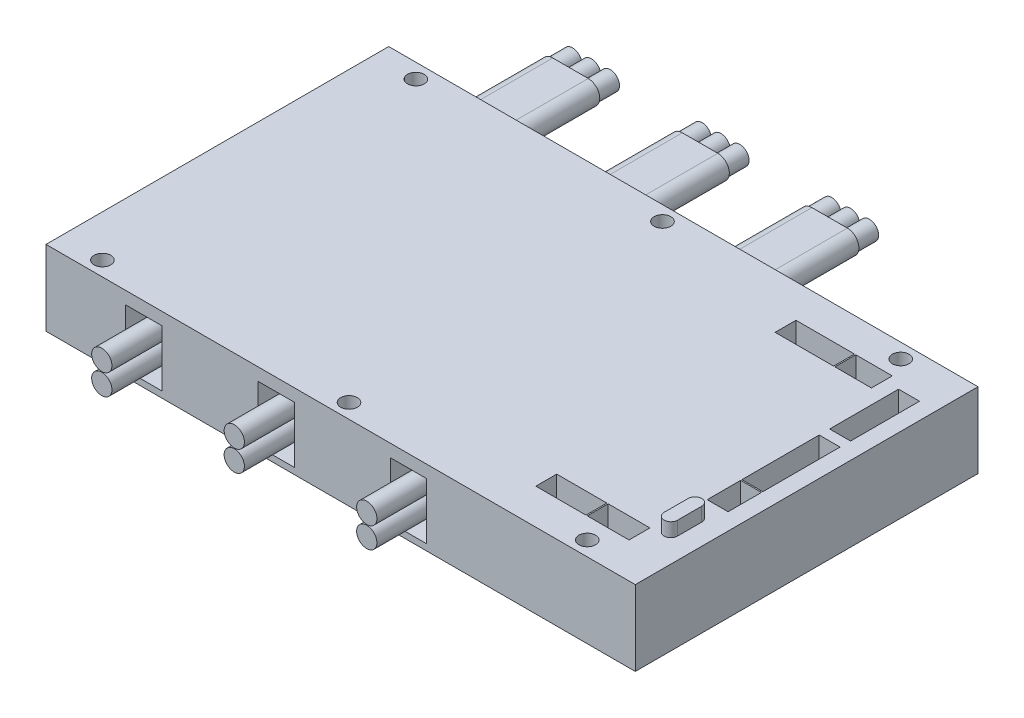
from build123d import *

# Parameters (mm, degrees)
SKETCH1_W           = 141
SKETCH1_H           = 82
BOSS_EXTRUDE1_DEPTH = 9
SKETCH3_R           = 2
CUT_EXTRUDE1_DEPTH  = 19
SKETCH4_W           = 8.7
SKETCH4_H           = 13.5
CUT_EXTRUDE2_DEPTH  = 10
SKETCH5_W           = 20
SKETCH5_H           = 5
CUT_EXTRUDE3_DEPTH  = 10
SKETCH6_W           = 3.23
SKETCH6_H           = 5.77
BOSS_EXTRUDE2_DEPTH = 3.3
SKETCH7_R           = 2.425
BOSS_EXTRUDE3_DEPTH = 20
LPATTERN1_COUNT     = 3
LPATTERN1_PITCH     = 31.7
SKETCH8_W           = 8.5
SKETCH8_H           = 5
SKETCH8_H_2         = 0.25
BOSS_EXTRUDE4_DEPTH = 30
SKETCH10_R          = 2.225
BOSS_EXTRUDE6_DEPTH = 5
LPATTERN2_COUNT     = 3
LPATTERN2_PITCH     = 31
SKETCH9_W           = 12
SKETCH9_H           = 5
SKETCH9_W_2         = 10
SKETCH9_W_3         = 5
SKETCH9_H_2         = 8
SKETCH9_H_3         = 18.5
SKETCH9_H_4         = 16.5
SKETCH9_W_4         = 8.75
SKETCH9_W_5         = 14
CUT_EXTRUDE4_DEPTH  = 5


with BuildPart() as part:
    # Sketch1 → Boss-Extrude1 (new body, symmetric)
    with BuildSketch(Plane(origin=(0, 0, 0), x_dir=(1, 0, 0), z_dir=(0, 1, 0))):
        Rectangle(SKETCH1_W, SKETCH1_H)
    extrude(amount=BOSS_EXTRUDE1_DEPTH, both=True)

    # Sketch3 → Cut-Extrude1 (cut, through all)
    with BuildSketch(Plane(origin=(0, 9, 0), x_dir=(1, 0, 0), z_dir=(0, 1, 0))):
        with Locations((-60.5, 37.5)):
            Circle(SKETCH3_R)
        with Locations((-1.5, 37.5)):
            Circle(SKETCH3_R)
        with Locations((55.5, 37.5)):
            Circle(SKETCH3_R)
    cut_extrude1 = extrude(amount=-CUT_EXTRUDE1_DEPTH, mode=Mode.SUBTRACT)

    # Mirror1: Cut-Extrude1 across plane
    add(cut_extrude1.mirror(Plane.XY), mode=Mode.SUBTRACT)

    # Sketch4 → Cut-Extrude2 (cut)
    with BuildSketch(Plane.XY.offset(41)):
        with Locations((-47.15, -0.75)):
            Rectangle(SKETCH4_W, SKETCH4_H)
        with Locations((-15.45, -0.75)):
            Rectangle(SKETCH4_W, SKETCH4_H)
        with Locations((16.25, -0.75)):
            Rectangle(SKETCH4_W, SKETCH4_H)
    extrude(amount=-CUT_EXTRUDE2_DEPTH, mode=Mode.SUBTRACT)

    # Sketch5 → Cut-Extrude3 (cut)
    with BuildSketch(Plane(origin=(0, 0, -41), x_dir=(-1, 0, 0), z_dir=(0, 0, -1))):
        with Locations((47, 3.5)):
            Rectangle(SKETCH5_W, SKETCH5_H)
        with Locations((16, 3.5)):
            Rectangle(SKETCH5_W, SKETCH5_H)
        with Locations((-15, 3.5)):
            Rectangle(SKETCH5_W, SKETCH5_H)
    extrude(amount=-CUT_EXTRUDE3_DEPTH, mode=Mode.SUBTRACT)

    # Sketch6 → Boss-Extrude2 (add)
    with BuildSketch(Plane(origin=(0, 9, 0), x_dir=(1, 0, 0), z_dir=(0, 1, 0))):
        with Locations((63.885, -23)):
            Rectangle(SKETCH6_W, SKETCH6_H)
        with BuildLine():
            Line((62.27, -20.115), (65.5, -20.115))
            ThreePointArc((65.5, -20.115), (63.885, -18.5), (62.27, -20.115))
        make_face()
        with BuildLine():
            ThreePointArc((65.5, -25.885), (63.885, -27.5), (62.27, -25.885))
            Line((62.27, -25.885), (65.5, -25.885))
        make_face()
    extrude(amount=BOSS_EXTRUDE2_DEPTH)

    # Sketch7 → Boss-Extrude3 (add)
    with BuildSketch(Plane.XY.offset(31)):
        with Locations((-47.15, 1.75)):
            Circle(SKETCH7_R)
        with Locations((-47.15, -3.25)):
            Circle(SKETCH7_R)
    boss_extrude3 = extrude(amount=BOSS_EXTRUDE3_DEPTH)

    # LPattern1: Boss-Extrude3 ×3
    with Locations(*[(i * LPATTERN1_PITCH, 0, 0) for i in range(1, LPATTERN1_COUNT)]):
        add(boss_extrude3)

    # Sketch8 → Boss-Extrude4 (add)
    with BuildSketch(Plane(origin=(0, 0, -31), x_dir=(-1, 0, 0), z_dir=(0, 0, -1))):
        with Locations((47, 3.5)):
            Rectangle(SKETCH8_W, SKETCH8_H)
        with BuildLine():
            Line((51.25, 6), (51.25, 1))
            Line((51.25, 1), (52.395643924, 1))
            ThreePointArc((52.395643924, 1), (54, 3.5), (52.395643924, 6))
            Line((52.395643924, 6), (51.25, 6))
        make_face()
        with BuildLine():
            Line((41.604356076, 1), (42.75, 1))
            Line((42.75, 1), (42.75, 6))
            Line((42.75, 6), (41.604356076, 6))
            ThreePointArc((41.604356076, 6), (40, 3.5), (41.604356076, 1))
        make_face()
        with Locations((47, 6.125)):
            Rectangle(SKETCH8_W, SKETCH8_H_2)
        with BuildLine():
            Line((51.25, 6.25), (51.25, 6))
            Line((51.25, 6), (52.395643924, 6))
            ThreePointArc((52.395643924, 6), (51.83630197, 6.186773158), (51.25, 6.25))
        make_face()
        with BuildLine():
            Line((41.604356076, 6), (42.75, 6))
            Line((42.75, 6), (42.75, 6.25))
            ThreePointArc((42.75, 6.25), (42.16369803, 6.186773158), (41.604356076, 6))
        make_face()
        with BuildLine():
            ThreePointArc((41.604356076, 1), (42.16369803, 0.813226842), (42.75, 0.75))
            Line((42.75, 0.75), (42.75, 1))
            Line((42.75, 1), (41.604356076, 1))
        make_face()
        with Locations((47, 0.875)):
            Rectangle(SKETCH8_W, SKETCH8_H_2)
        with BuildLine():
            Line((51.25, 1), (51.25, 0.75))
            ThreePointArc((51.25, 0.75), (51.83630197, 0.813226842), (52.395643924, 1))
            Line((52.395643924, 1), (51.25, 1))
        make_face()
    boss_extrude4 = extrude(amount=BOSS_EXTRUDE4_DEPTH)

    # Sketch10 → Boss-Extrude6 (add)
    with BuildSketch(Plane(origin=(0, 0, -61), x_dir=(-1, 0, 0), z_dir=(0, 0, -1))):
        with Locations((51.5, 3.5)):
            Circle(SKETCH10_R)
        with Locations((47, 3.5)):
            Circle(SKETCH10_R)
        with Locations((42.5, 3.5)):
            Circle(SKETCH10_R)
    boss_extrude6 = extrude(amount=BOSS_EXTRUDE6_DEPTH)

    # LPattern2: Boss-Extrude4, Boss-Extrude6 ×3
    with Locations(*[(i * LPATTERN2_PITCH, 0, 0) for i in range(1, LPATTERN2_COUNT)]):
        add(boss_extrude4)
        add(boss_extrude6)

    # Sketch9 → Cut-Extrude4 (cut)
    with BuildSketch(Plane(origin=(0, 9, 0), x_dir=(1, 0, 0), z_dir=(0, 1, 0))):
        with Locations((44.2, -30)):
            Rectangle(SKETCH9_W, SKETCH9_H)
        with Locations((55.5, -30)):
            Rectangle(SKETCH9_W_2, SKETCH9_H)
        with Locations((64, -10.8)):
            Rectangle(SKETCH9_W_3, SKETCH9_H_2)
        with Locations((64, 2.75)):
            Rectangle(SKETCH9_W_3, SKETCH9_H_3)
        with Locations((64, 22.75)):
            Rectangle(SKETCH9_W_3, SKETCH9_H_4)
        with Locations((53.625, 30.5)):
            Rectangle(SKETCH9_W_4, SKETCH9_H)
        with Locations((41.95, 30.5)):
            Rectangle(SKETCH9_W_5, SKETCH9_H)
    extrude(amount=-CUT_EXTRUDE4_DEPTH, mode=Mode.SUBTRACT)


solid = part.part
